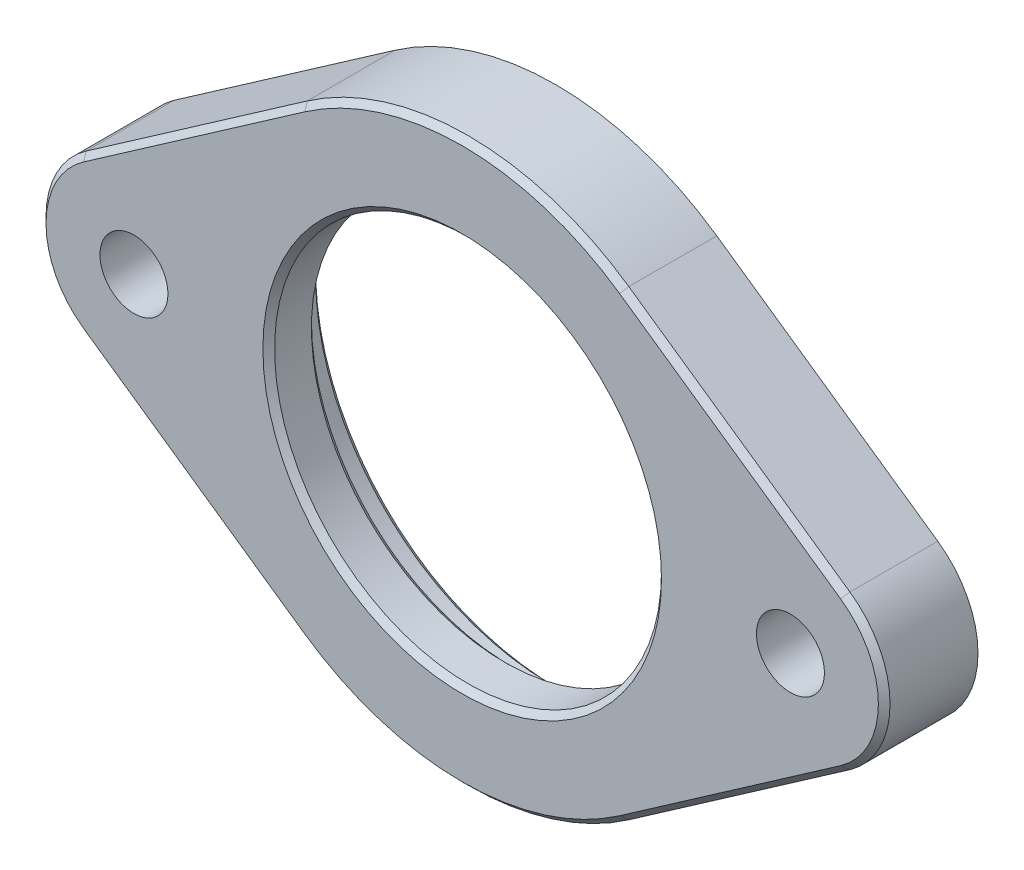
from build123d import *

# Parameters (mm, degrees)
BOSS_EXTRUDE1_DEPTH     = 4
CUT_EXTRUDE1_DEPTH      = 23
CUT_EXTRUDE1_DEPTH_BACK = 23
SKETCH1_4_R             = 8.25
CUT_EXTRUDE2_DEPTH      = 1.93
CUT_EXTRUDE2_DEPTH_BACK = 23
SKETCH1_6_R             = 10
M2_5_CLEARANCE_HOLE1_D  = 2.9
CHAMFER1_SIZE           = 0.25


with BuildPart() as part:
    # Sketch1 → Boss-Extrude1 (new body)
    with BuildSketch(Plane.XY):
        with BuildLine():
            ThreePointArc((6.857142857, 9.84782168), (0, 12), (-6.857142857, 9.84782168))
            Line((-6.857142857, 9.84782168), (-16.285714286, 3.282607227))
            ThreePointArc((-16.285714286, 3.282607227), (-18, 0), (-16.285714286, -3.282607227))
            Line((-16.285714286, -3.282607227), (-6.857142857, -9.84782168))
            ThreePointArc((-6.857142857, -9.84782168), (0, -12), (6.857142857, -9.84782168))
            Line((6.857142857, -9.84782168), (16.285714286, -3.282607227))
            ThreePointArc((16.285714286, -3.282607227), (18, 0), (16.285714286, 3.282607227))
            Line((16.285714286, 3.282607227), (6.857142857, 9.84782168))
        make_face()
    extrude(amount=BOSS_EXTRUDE1_DEPTH)

    # Sketch1_4 → Cut-Extrude1 (cut, two sides: drawn at the far end of the back side and taken through both)
    with BuildSketch(Plane.XY.offset(-CUT_EXTRUDE1_DEPTH_BACK)):
        Circle(SKETCH1_4_R)
    extrude(amount=CUT_EXTRUDE1_DEPTH + CUT_EXTRUDE1_DEPTH_BACK, mode=Mode.SUBTRACT)

    # Sketch1_6 → Cut-Extrude2 (cut, two sides: drawn at the far end of the back side and taken through both)
    with BuildSketch(Plane.XY.offset(-CUT_EXTRUDE2_DEPTH_BACK)):
        Circle(SKETCH1_6_R)
    extrude(amount=CUT_EXTRUDE2_DEPTH + CUT_EXTRUDE2_DEPTH_BACK, mode=Mode.SUBTRACT)

    # M2.5 Clearance Hole1 (through all)
    with Locations(Plane.XY.offset(4)):
        with Locations((-14, 0), (14, 0)):
            Hole(M2_5_CLEARANCE_HOLE1_D / 2)

    # Chamfer1
    chamfer1_edges = [part.edges().sort_by_distance(p)[0] for p in [
        (-8.25, 0, 4),
        (-8.25, 0, 1.93),
        (-10, 0, 0),
        (-10, 0, 1.93),
        (0, -12, 4),
        (11.571428571, -6.565214453, 4),
        (-11.571428571, -6.565214453, 4),
        (18, 0, 4),
        (-18, 0, 4),
        (11.571428571, 6.565214453, 4),
        (-11.571428571, 6.565214453, 4),
        (0, 12, 4),
    ]]
    chamfer(chamfer1_edges, length=CHAMFER1_SIZE)


solid = part.part
